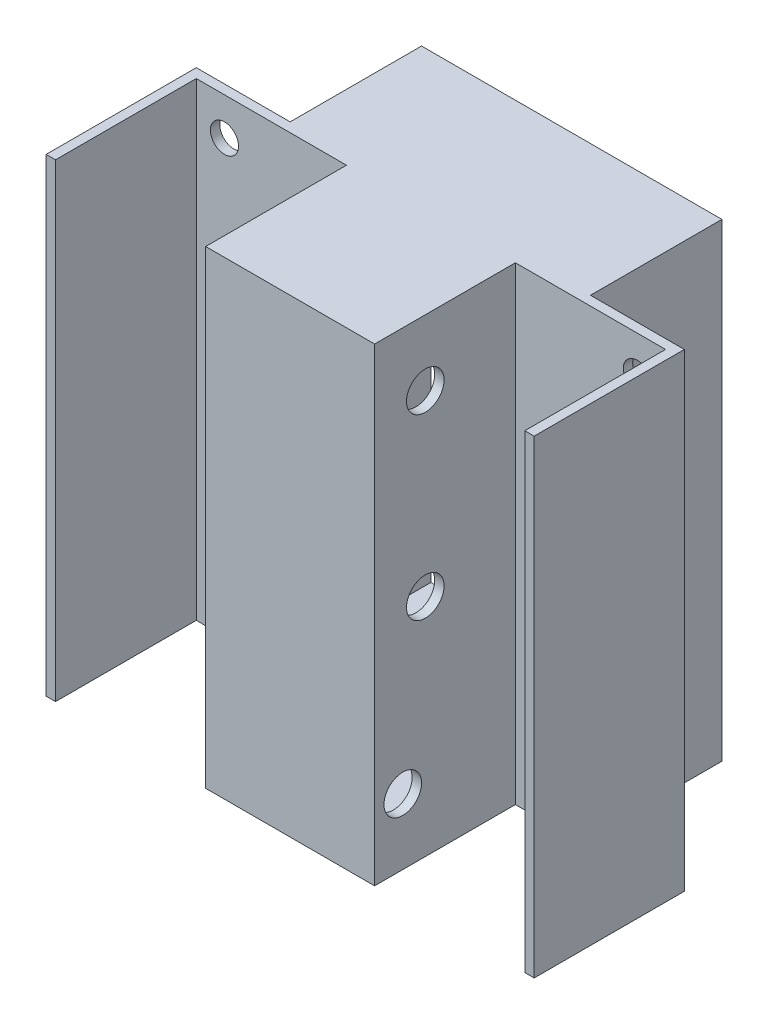
from build123d import *

# Parameters (mm, degrees)
ESQUISSE1_W             = 90
ESQUISSE1_H             = 250
BOSS_EXTRU_1_DEPTH      = 5
ESQUISSE2_W             = 90
ESQUISSE2_H             = 250
ESQUISSE2_W_2           = 80
ESQUISSE2_H_2           = 240
BOSS_EXTRU_2_DEPTH      = 70
BOSS_EXTRU_3_DEPTH      = 5
ESQUISSE4_R             = 10
ENL_V_MAT_EXTRU_2_DEPTH = 171
ESQUISSE5_W             = 80
ESQUISSE5_H             = 250
BOSS_EXTRU_4_DEPTH      = 5
ESQUISSE6_W             = 80
ESQUISSE6_H             = 250
BOSS_EXTRU_5_DEPTH      = 5
ESQUISSE7_W             = 160
ESQUISSE7_H             = 250
ESQUISSE7_W_2           = 150
ESQUISSE7_H_2           = 240
BOSS_EXTRU_6_DEPTH      = 70
ESQUISSE10_R            = 7.5
ENL_V_MAT_EXTRU_3_DEPTH = 50


with BuildPart() as part:
    # Esquisse1 → Boss.-Extru.1 (new body)
    with BuildSketch(Plane.XY):
        with Locations((-45, 125)):
            Rectangle(ESQUISSE1_W, ESQUISSE1_H)
    extrude(amount=BOSS_EXTRU_1_DEPTH)

    # Esquisse2 → Boss.-Extru.2 (add)
    with BuildSketch(Plane(origin=(0, 0, 0), x_dir=(-1, 0, 0), z_dir=(0, 0, -1))):
        with Locations((45, 125)):
            Rectangle(ESQUISSE2_W, ESQUISSE2_H)
        with Locations((45, 125)):
            Rectangle(ESQUISSE2_W_2, ESQUISSE2_H_2, mode=Mode.SUBTRACT)
    extrude(amount=BOSS_EXTRU_2_DEPTH)

    # Esquisse3 → Boss.-Extru.3 (add)
    with BuildSketch(Plane(origin=(0, 0, -70), x_dir=(-1, 0, 0), z_dir=(0, 0, -1))):
        Polygon((6.025463364, 250), (-80, 250), (-80, 0), (-15, 0), (45, 0), (45, 5), (5, 5), (5, 245), (45, 245), (45, 250), align=None)
    boss_extru_3 = extrude(amount=BOSS_EXTRU_3_DEPTH)

    # Symétrie1: Boss.-Extru.3 across plane
    add(boss_extru_3.mirror(Plane(origin=(-45, 245, -75), x_dir=(0, 0, 1), z_dir=(1, 0, 0))))

    # Esquisse4 → Enlèv. mat.-Extru.2 (cut, through all)
    with BuildSketch(Plane.ZY.offset(90)):
        with Locations((-22, 215)):
            Circle(ESQUISSE4_R)
        with Locations((-22, 120)):
            Circle(ESQUISSE4_R)
        with Locations((-10, 35)):
            Circle(ESQUISSE4_R)
    extrude(amount=-ENL_V_MAT_EXTRU_2_DEPTH, mode=Mode.SUBTRACT)

    # Esquisse5 → Boss.-Extru.4 (add)
    with BuildSketch(Plane(origin=(80, 0, 0), x_dir=(0, 0, -1), z_dir=(1, 0, 0))):
        with Locations((35, 125)):
            Rectangle(ESQUISSE5_W, ESQUISSE5_H)
    extrude(amount=BOSS_EXTRU_4_DEPTH)

    # Esquisse6 → Boss.-Extru.5 (add)
    with BuildSketch(Plane.ZY.offset(170)):
        with Locations((-35, 125)):
            Rectangle(ESQUISSE6_W, ESQUISSE6_H)
    extrude(amount=BOSS_EXTRU_5_DEPTH)

    # Esquisse7 → Boss.-Extru.6 (add)
    with BuildSketch(Plane(origin=(0, 0, -75), x_dir=(-1, 0, 0), z_dir=(0, 0, -1))):
        with Locations((45, 125)):
            Rectangle(ESQUISSE7_W, ESQUISSE7_H)
        with Locations((45, 125)):
            Rectangle(ESQUISSE7_W_2, ESQUISSE7_H_2, mode=Mode.SUBTRACT)
    extrude(amount=BOSS_EXTRU_6_DEPTH)

    # Esquisse10 → Enlèv. mat.-Extru.3 (cut)
    with BuildSketch(Plane(origin=(0, 0, -75), x_dir=(-1, 0, 0), z_dir=(0, 0, -1))):
        with Locations((155, 230)):
            Circle(ESQUISSE10_R)
        with Locations((-65, 230)):
            Circle(ESQUISSE10_R)
        with Locations((-65, 160)):
            Circle(ESQUISSE10_R)
        with Locations((155, 160)):
            Circle(ESQUISSE10_R)
        with Locations((-65, 90)):
            Circle(ESQUISSE10_R)
        with Locations((155, 90)):
            Circle(ESQUISSE10_R)
        with Locations((-65, 20)):
            Circle(ESQUISSE10_R)
        with Locations((155, 20)):
            Circle(ESQUISSE10_R)
    extrude(amount=-ENL_V_MAT_EXTRU_3_DEPTH, mode=Mode.SUBTRACT)


solid = part.part
